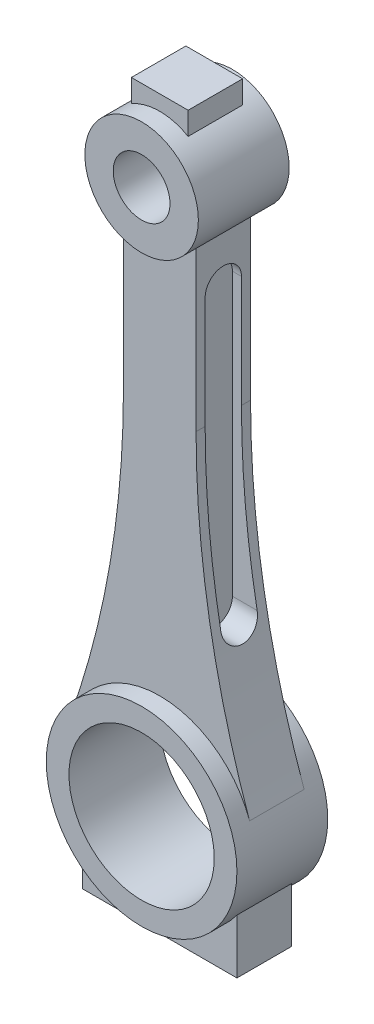
from build123d import *

# Parameters (mm, degrees)
SKETCH1_R             = 21
SKETCH1_R_2           = 16
BOSS_EXTRUDE1_DEPTH   = 10
SKETCH1_R_3           = 12.5
SKETCH1_R_4           = 6.25
BOSS_EXTRUDE1_2_DEPTH = 10
BOSS_EXTRUDE3_DEPTH   = 6
BOSS_EXTRUDE4_DEPTH   = 6
BOSS_EXTRUDE5_DEPTH   = 6
CUT_EXTRUDE1_START    = 6
CUT_EXTRUDE1_DEPTH    = 16
CUT_EXTRUDE2_START    = -6
CUT_EXTRUDE2_DEPTH    = 16


with BuildPart() as part:
    # Sketch1 → Boss-Extrude1 (new body, symmetric)
    with BuildSketch(Plane.XY):
        Circle(SKETCH1_R)
        Circle(SKETCH1_R_2, mode=Mode.SUBTRACT)
    extrude(amount=BOSS_EXTRUDE1_DEPTH, both=True)



with BuildPart() as body_2:
    # Sketch1 → Boss-Extrude1 2 (new body, symmetric)
    with BuildSketch(Plane.XY):
        with Locations((0, 120)):
            Circle(SKETCH1_R_3)
        with Locations((0, 120)):
            Circle(SKETCH1_R_4, mode=Mode.SUBTRACT)
    extrude(amount=BOSS_EXTRUDE1_2_DEPTH, both=True)


with BuildPart() as part_1:
    add(part.part)

    add(body_2.part)  # Boss-Extrude3 merges body 2
    # Sketch1_5 → Boss-Extrude3 (add, symmetric)
    with BuildSketch(Plane.XY):
        with BuildLine():
            ThreePointArc((8, 110.395313644), (0, 107.5), (-8, 110.395313644))
            Line((-8, 110.395313644), (-8, 75.395313644))
            ThreePointArc((-8, 75.395313644), (-10.96842855, 40.709642053), (-19.787382488, 7.032744434))
            ThreePointArc((-19.787382488, 7.032744434), (0, 21), (19.787382488, 7.032744434))
            ThreePointArc((19.787382488, 7.032744434), (10.96842855, 40.709642053), (8, 75.395313644))
            Line((8, 75.395313644), (8, 110.395313644))
        make_face()
    extrude(amount=BOSS_EXTRUDE3_DEPTH, both=True)

    # Sketch1_6 → Boss-Extrude4 (add, symmetric)
    with BuildSketch(Plane.XY):
        with BuildLine():
            Line((-6.25, 135.825317547), (-6.25, 130.825317547))
            ThreePointArc((-6.25, 130.825317547), (0, 132.5), (6.25, 130.825317547))
            Line((6.25, 130.825317547), (6.25, 135.825317547))
            Line((6.25, 135.825317547), (-6.25, 135.825317547))
        make_face()
    extrude(amount=BOSS_EXTRUDE4_DEPTH, both=True)

    # Sketch1_7 → Boss-Extrude5 (add, symmetric)
    with BuildSketch(Plane.XY):
        with BuildLine():
            ThreePointArc((17, -12.328828006), (0, -21), (-17, -12.328828006))
            Line((-17, -12.328828006), (-17, -24.328828006))
            Line((-17, -24.328828006), (17, -24.328828006))
            Line((17, -24.328828006), (17, -12.328828006))
        make_face()
    extrude(amount=BOSS_EXTRUDE5_DEPTH, both=True)

    # Sketch2 → Cut-Extrude1 (cut, through all)
    with BuildSketch(Plane(origin=(0, 0, 0), x_dir=(0, 0, -1), z_dir=(1, 0, 0)).offset(CUT_EXTRUDE1_START)):
        with BuildLine():
            Line((4, 100), (4, 38))
            ThreePointArc((4, 38), (0, 34), (-4, 38))
            Line((-4, 38), (-4, 100))
            ThreePointArc((-4, 100), (0, 104), (4, 100))
        make_face()
    extrude(amount=CUT_EXTRUDE1_DEPTH, mode=Mode.SUBTRACT)

    # Sketch2_2 → Cut-Extrude2 (cut, through all)
    with BuildSketch(Plane(origin=(0, 0, 0), x_dir=(0, 0, -1), z_dir=(1, 0, 0)).offset(CUT_EXTRUDE2_START)):
        with BuildLine():
            Line((4, 100), (4, 38))
            ThreePointArc((4, 38), (0, 34), (-4, 38))
            Line((-4, 38), (-4, 100))
            ThreePointArc((-4, 100), (0, 104), (4, 100))
        make_face()
    extrude(amount=-CUT_EXTRUDE2_DEPTH, mode=Mode.SUBTRACT)


solid = part_1.part
